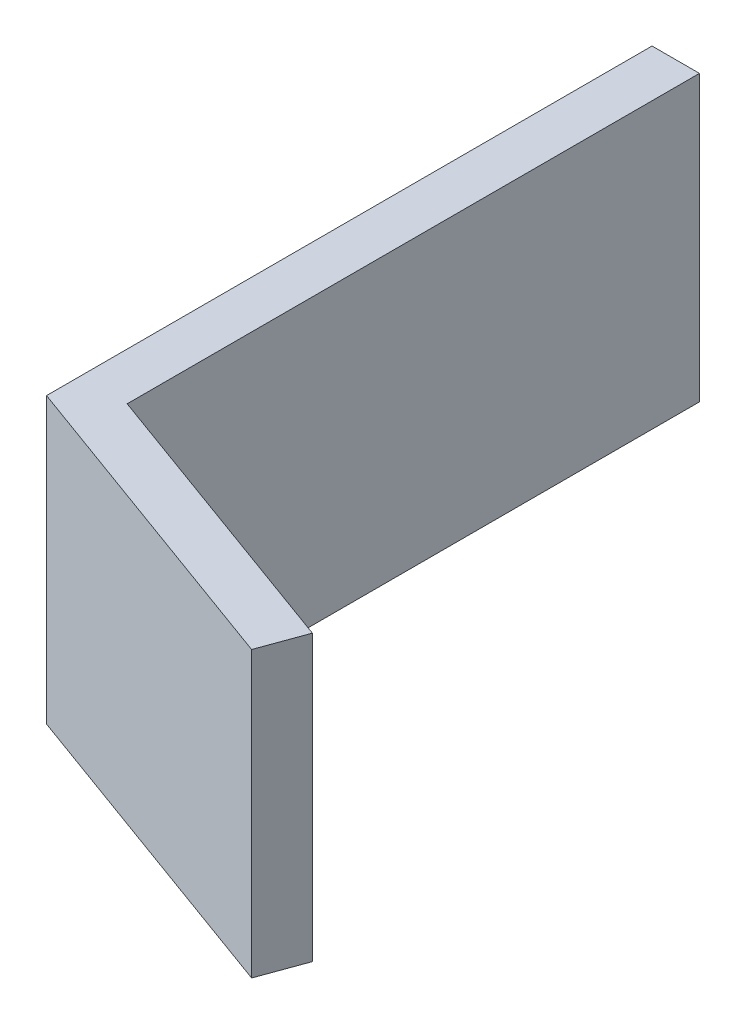
from build123d import *

# Parameters (mm, degrees)
BOSS_EXTRUDE1_DEPTH = 19.05


with BuildPart() as part:
    # Sketch1 → Boss-Extrude1 (new body)
    with BuildSketch(Plane(origin=(0, 0, 0), x_dir=(1, 0, 0), z_dir=(0, 1, 0))):
        Polygon((-47.971294585, -10.735882573), (-47.971294585, -51.281055704), (-26.381294585, -59.139173062), (-25.29538063, -56.155648991), (-44.796294585, -49.05789677), (-44.796294585, -10.735882573), align=None)
    extrude(amount=BOSS_EXTRUDE1_DEPTH)


solid = part.part
